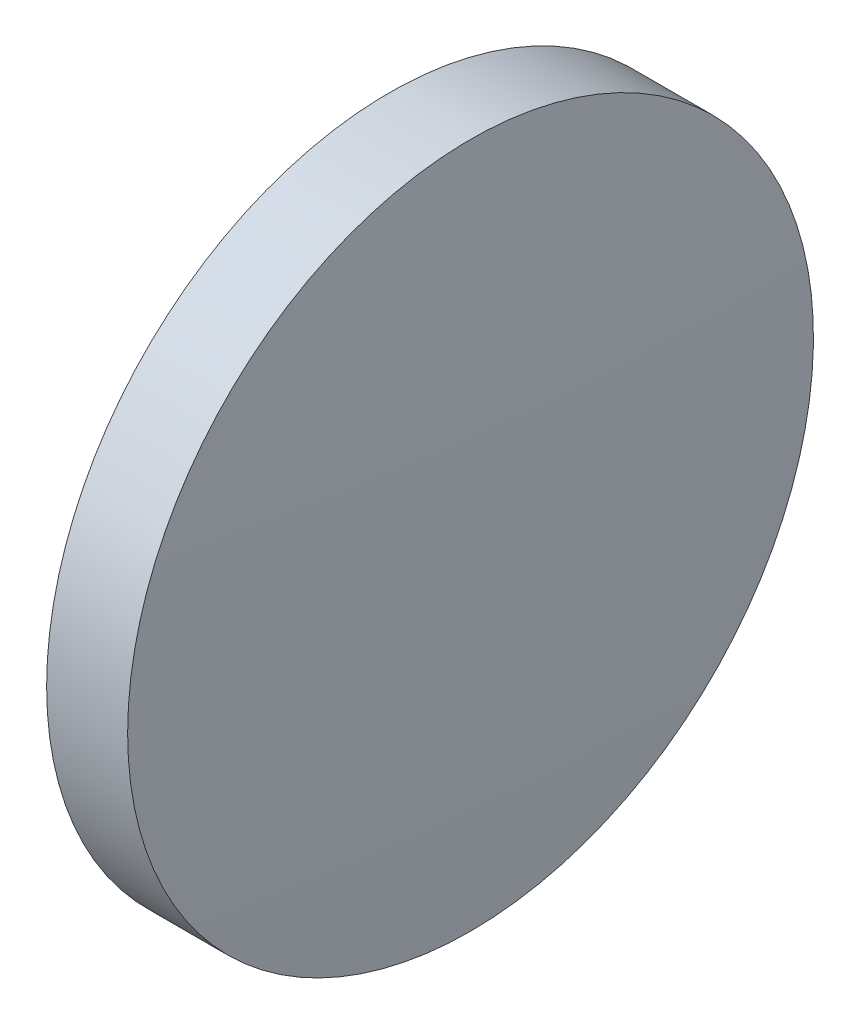
from build123d import *


with BuildPart() as part:
    # 草图1 → 旋转1 (revolve)
    with BuildSketch(Plane.XY, mode=Mode.PRIVATE) as revolve_1_sk:
        with BuildLine():
            Line((115.773606431, 65.233554926), (115.773606431, 77.933554926))
            Line((115.773606431, 77.933554926), (118.773942667, 77.933554926))
            ThreePointArc((118.773942667, 77.933554926), (119.037673644, 71.585988858), (119.125606431, 65.233554926))
            Line((119.125606431, 65.233554926), (115.773606431, 65.233554926))
        make_face()
    revolve(revolve_1_sk.sketch.rotate(Axis((110.165373228, 65.233554926, 0), (1, 0, 0)), 180), axis=Axis((110.165373228, 65.233554926, 0), (1, 0, 0)))  # turned: the seam where the file's is


solid = part.part
